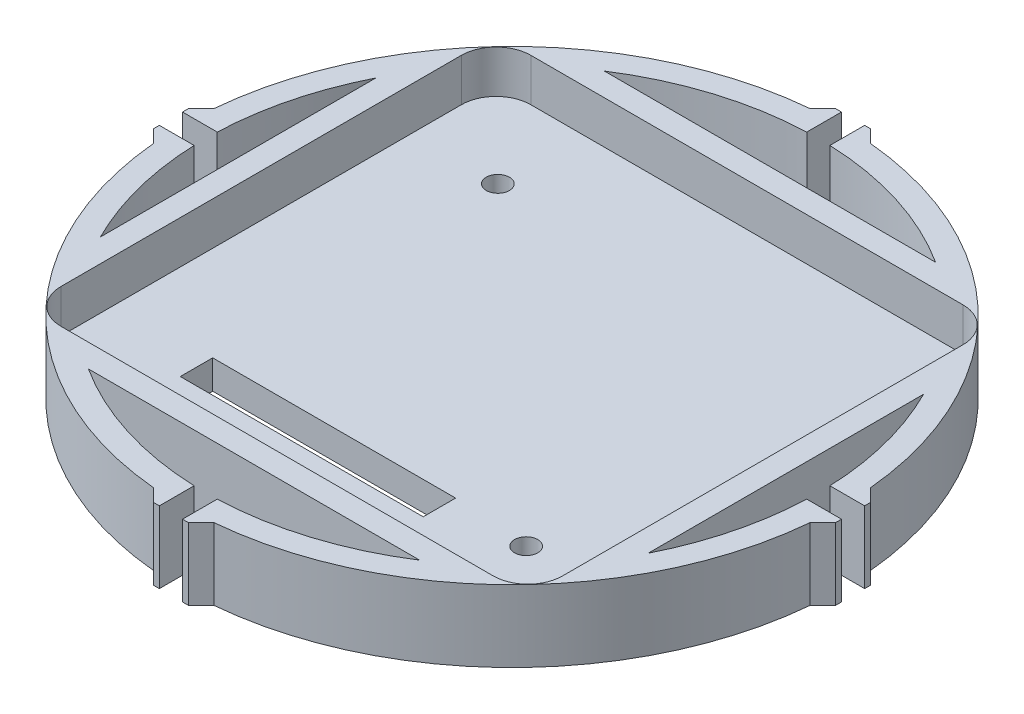
from build123d import *

# Parameters (mm, degrees)
SKETCH1_R           = 28.5
BOSS_EXTRUDE1_DEPTH = 6.2
CUT_EXTRUDE1_DEPTH  = 3.7
CUT_EXTRUDE2_REACH  = 42.475
SKETCH3_R           = 1
SKETCH3_W           = 21
SKETCH3_H           = 2.8
CUT_EXTRUDE3_REACH  = 42.779
BOSS_EXTRUDE2_DEPTH = 6.2


with BuildPart() as part:
    # Sketch1 → Boss-Extrude1 (new body)
    with BuildSketch(Plane(origin=(0, 0, 0), x_dir=(1, 0, 0), z_dir=(0, 1, 0))):
        with Locations(Location((0, 0, 0), (0, 0, 90))):
            Circle(SKETCH1_R)
    extrude(amount=BOSS_EXTRUDE1_DEPTH)

    # Sketch2 → Cut-Extrude1 (cut)
    with BuildSketch(Plane(origin=(0, 6.2, 0), x_dir=(1, 0, 0), z_dir=(0, 1, 0))):
        with BuildLine():
            Line((18.675, 20.3), (-18.675, 20.3))
            ThreePointArc((-18.675, 20.3), (-20.796320344, 19.421320344), (-21.675, 17.3))
            Line((-21.675, 17.3), (-21.675, -17.3))
            ThreePointArc((-21.675, -17.3), (-20.796320374, -19.421320313), (-18.675000086, -20.3))
            Line((-18.675000086, -20.3), (18.675, -20.3))
            ThreePointArc((18.675, -20.3), (20.796320344, -19.421320344), (21.675, -17.3))
            Line((21.675, -17.3), (21.675, 17.3))
            ThreePointArc((21.675, 17.3), (20.796320344, 19.421320344), (18.675, 20.3))
        make_face()
    extrude(amount=-CUT_EXTRUDE1_DEPTH, mode=Mode.SUBTRACT)

    # Sketch3 → Cut-Extrude2 (cut, up to next)
    with BuildSketch(Plane(origin=(0, 2.5, 0), x_dir=(1, 0, 0), z_dir=(0, 1, 0)), mode=Mode.PRIVATE) as cut_extrude2_sk1:
        with Locations(Location((-14.175, 12.95, 0), (0, 0, 270))):
            Circle(SKETCH3_R)
    cut_extrude2_tool1 = extrude(cut_extrude2_sk1.sketch, amount=-CUT_EXTRUDE2_REACH, mode=Mode.PRIVATE) & part.part
    # Sketch3 → Cut-Extrude2 (cut, up to next)
    with BuildSketch(Plane(origin=(0, 2.5, 0), x_dir=(1, 0, 0), z_dir=(0, 1, 0)), mode=Mode.PRIVATE) as cut_extrude2_sk2:
        with Locations((-2.975, -13.8)):
            Rectangle(SKETCH3_W, SKETCH3_H)
    cut_extrude2_tool2 = extrude(cut_extrude2_sk2.sketch, amount=-CUT_EXTRUDE2_REACH, mode=Mode.PRIVATE) & part.part
    # Sketch3 → Cut-Extrude2 (cut, up to next)
    with BuildSketch(Plane(origin=(0, 2.5, 0), x_dir=(1, 0, 0), z_dir=(0, 1, 0)), mode=Mode.PRIVATE) as cut_extrude2_sk3:
        with Locations(Location((14.175, -12.95, 0), (0, 0, 270))):
            Circle(SKETCH3_R)
    cut_extrude2_tool3 = extrude(cut_extrude2_sk3.sketch, amount=-CUT_EXTRUDE2_REACH, mode=Mode.PRIVATE) & part.part
    add(cut_extrude2_tool1.solids().sort_by_distance((-14.175, 2.5, -12.95))[0], mode=Mode.SUBTRACT)
    add(cut_extrude2_tool2.solids().sort_by_distance((-2.975, 2.5, 13.8))[0], mode=Mode.SUBTRACT)
    add(cut_extrude2_tool3.solids().sort_by_distance((14.175, 2.5, 12.95))[0], mode=Mode.SUBTRACT)

    # Sketch4 → Cut-Extrude3 (cut, up to next)
    with BuildSketch(Plane(origin=(0, 6.2, 0), x_dir=(1, 0, 0), z_dir=(0, 1, 0)), mode=Mode.PRIVATE) as cut_extrude3_sk1:
        with BuildLine():
            ThreePointArc((-1, 26.481125354), (-7.938429591, 25.283024653), (-14.316424135, 22.3))
            Line((-14.316424135, 22.3), (-1, 22.3))
            Line((-1, 22.3), (-1, 26.481125354))
        make_face()
    cut_extrude3_tool1 = extrude(cut_extrude3_sk1.sketch, amount=-CUT_EXTRUDE3_REACH, mode=Mode.PRIVATE) & part.part
    # Sketch4 → Cut-Extrude3 (cut, up to next)
    with BuildSketch(Plane(origin=(0, 6.2, 0), x_dir=(1, 0, 0), z_dir=(0, 1, 0)), mode=Mode.PRIVATE) as cut_extrude3_sk2:
        with BuildLine():
            Line((1, 26.481125354), (1, 22.3))
            Line((1, 22.3), (14.316424135, 22.3))
            ThreePointArc((14.316424135, 22.3), (7.938429591, 25.283024653), (1, 26.481125354))
        make_face()
    cut_extrude3_tool2 = extrude(cut_extrude3_sk2.sketch, amount=-CUT_EXTRUDE3_REACH, mode=Mode.PRIVATE) & part.part
    # Sketch4 → Cut-Extrude3 (cut, up to next)
    with BuildSketch(Plane(origin=(0, 6.2, 0), x_dir=(1, 0, 0), z_dir=(0, 1, 0)), mode=Mode.PRIVATE) as cut_extrude3_sk3:
        with BuildLine():
            ThreePointArc((0, 28.5), (-0.500076988, 28.495612347), (-1, 28.482450737))
            Line((-1, 28.482450737), (-1, 26.481125354))
            ThreePointArc((-1, 26.481125354), (0, 26.5), (1, 26.481125354))
            Line((1, 26.481125354), (1, 28.482450737))
            ThreePointArc((1, 28.482450737), (0.500076988, 28.495612347), (0, 28.5))
        make_face()
    cut_extrude3_tool3 = extrude(cut_extrude3_sk3.sketch, amount=-CUT_EXTRUDE3_REACH, mode=Mode.PRIVATE) & part.part
    # Sketch4 → Cut-Extrude3 (cut, up to next)
    with BuildSketch(Plane(origin=(0, 6.2, 0), x_dir=(1, 0, 0), z_dir=(0, 1, 0)), mode=Mode.PRIVATE) as cut_extrude3_sk4:
        with BuildLine():
            Line((-1, -26.481125354), (-1, -28.482450737))
            ThreePointArc((-1, -28.482450737), (-0.500077047, -28.495612346), (-1.18e-07, -28.5))
            ThreePointArc((-1.18e-07, -28.5), (0.500076929, -28.495612348), (1, -28.482450737))
            Line((1, -28.482450737), (1, -26.481125354))
            ThreePointArc((1, -26.481125354), (0, -26.5), (-1, -26.481125354))
        make_face()
    cut_extrude3_tool4 = extrude(cut_extrude3_sk4.sketch, amount=-CUT_EXTRUDE3_REACH, mode=Mode.PRIVATE) & part.part
    # Sketch4 → Cut-Extrude3 (cut, up to next)
    with BuildSketch(Plane(origin=(0, 6.2, 0), x_dir=(1, 0, 0), z_dir=(0, 1, 0)), mode=Mode.PRIVATE) as cut_extrude3_sk5:
        with BuildLine():
            Line((-1, 26.481125354), (-1, 22.3))
            Line((-1, 22.3), (1, 22.3))
            Line((1, 22.3), (1, 26.481125354))
            ThreePointArc((1, 26.481125354), (0, 26.5), (-1, 26.481125354))
        make_face()
    cut_extrude3_tool5 = extrude(cut_extrude3_sk5.sketch, amount=-CUT_EXTRUDE3_REACH, mode=Mode.PRIVATE) & part.part
    # Sketch4 → Cut-Extrude3 (cut, up to next)
    with BuildSketch(Plane(origin=(0, 6.2, 0), x_dir=(1, 0, 0), z_dir=(0, 1, 0)), mode=Mode.PRIVATE) as cut_extrude3_sk6:
        with BuildLine():
            Line((-26.481125354, 1), (-28.482450737, 1))
            ThreePointArc((-28.482450737, 1), (-28.495612347, 0.500076988), (-28.5, 0))
            ThreePointArc((-28.5, 0), (-28.495612347, -0.500076988), (-28.482450737, -1))
            Line((-28.482450737, -1), (-26.481125354, -1))
            ThreePointArc((-26.481125354, -1), (-26.5, 0), (-26.481125354, 1))
        make_face()
    cut_extrude3_tool6 = extrude(cut_extrude3_sk6.sketch, amount=-CUT_EXTRUDE3_REACH, mode=Mode.PRIVATE) & part.part
    # Sketch4 → Cut-Extrude3 (cut, up to next)
    with BuildSketch(Plane(origin=(0, 6.2, 0), x_dir=(1, 0, 0), z_dir=(0, 1, 0)), mode=Mode.PRIVATE) as cut_extrude3_sk7:
        with BuildLine():
            Line((28.482450737, 1), (26.481125354, 1))
            ThreePointArc((26.481125354, 1), (26.495280918, 0.500089055), (26.5, 0))
            ThreePointArc((26.5, 0), (26.495280918, -0.500089055), (26.481125354, -1))
            Line((26.481125354, -1), (28.482450737, -1))
            ThreePointArc((28.482450737, -1), (28.495612347, -0.500076988), (28.5, 0))
            ThreePointArc((28.5, 0), (28.495612347, 0.500076988), (28.482450737, 1))
        make_face()
    cut_extrude3_tool7 = extrude(cut_extrude3_sk7.sketch, amount=-CUT_EXTRUDE3_REACH, mode=Mode.PRIVATE) & part.part
    # Sketch4 → Cut-Extrude3 (cut, up to next)
    with BuildSketch(Plane(origin=(0, 6.2, 0), x_dir=(1, 0, 0), z_dir=(0, 1, 0)), mode=Mode.PRIVATE) as cut_extrude3_sk8:
        with BuildLine():
            Line((-23.675, 1), (-26.481125354, 1))
            ThreePointArc((-26.481125354, 1), (-26.5, 0), (-26.481125354, -1))
            Line((-26.481125354, -1), (-23.675, -1))
            Line((-23.675, -1), (-23.675, 1))
        make_face()
    cut_extrude3_tool8 = extrude(cut_extrude3_sk8.sketch, amount=-CUT_EXTRUDE3_REACH, mode=Mode.PRIVATE) & part.part
    # Sketch4 → Cut-Extrude3 (cut, up to next)
    with BuildSketch(Plane(origin=(0, 6.2, 0), x_dir=(1, 0, 0), z_dir=(0, 1, 0)), mode=Mode.PRIVATE) as cut_extrude3_sk9:
        with BuildLine():
            ThreePointArc((-23.675, 11.90564467), (-25.664031231, 6.603597577), (-26.481125354, 1))
            Line((-26.481125354, 1), (-23.675, 1))
            Line((-23.675, 1), (-23.675, 11.90564467))
        make_face()
    cut_extrude3_tool9 = extrude(cut_extrude3_sk9.sketch, amount=-CUT_EXTRUDE3_REACH, mode=Mode.PRIVATE) & part.part
    # Sketch4 → Cut-Extrude3 (cut, up to next)
    with BuildSketch(Plane(origin=(0, 6.2, 0), x_dir=(1, 0, 0), z_dir=(0, 1, 0)), mode=Mode.PRIVATE) as cut_extrude3_sk10:
        with BuildLine():
            Line((-23.675, -1), (-26.481125354, -1))
            ThreePointArc((-26.481125354, -1), (-25.664031231, -6.603597577), (-23.675, -11.90564467))
            Line((-23.675, -11.90564467), (-23.675, -1))
        make_face()
    cut_extrude3_tool10 = extrude(cut_extrude3_sk10.sketch, amount=-CUT_EXTRUDE3_REACH, mode=Mode.PRIVATE) & part.part
    # Sketch4 → Cut-Extrude3 (cut, up to next)
    with BuildSketch(Plane(origin=(0, 6.2, 0), x_dir=(1, 0, 0), z_dir=(0, 1, 0)), mode=Mode.PRIVATE) as cut_extrude3_sk11:
        with BuildLine():
            Line((-1, -22.3), (-14.316424135, -22.3))
            ThreePointArc((-14.316424135, -22.3), (-7.938429591, -25.283024653), (-1, -26.481125354))
            Line((-1, -26.481125354), (-1, -22.3))
        make_face()
    cut_extrude3_tool11 = extrude(cut_extrude3_sk11.sketch, amount=-CUT_EXTRUDE3_REACH, mode=Mode.PRIVATE) & part.part
    # Sketch4 → Cut-Extrude3 (cut, up to next)
    with BuildSketch(Plane(origin=(0, 6.2, 0), x_dir=(1, 0, 0), z_dir=(0, 1, 0)), mode=Mode.PRIVATE) as cut_extrude3_sk12:
        with BuildLine():
            Line((14.316424135, -22.3), (1, -22.3))
            Line((1, -22.3), (1, -26.481125354))
            ThreePointArc((1, -26.481125354), (7.938429591, -25.283024653), (14.316424135, -22.3))
        make_face()
    cut_extrude3_tool12 = extrude(cut_extrude3_sk12.sketch, amount=-CUT_EXTRUDE3_REACH, mode=Mode.PRIVATE) & part.part
    # Sketch4 → Cut-Extrude3 (cut, up to next)
    with BuildSketch(Plane(origin=(0, 6.2, 0), x_dir=(1, 0, 0), z_dir=(0, 1, 0)), mode=Mode.PRIVATE) as cut_extrude3_sk13:
        with BuildLine():
            Line((1, -22.3), (-1, -22.3))
            Line((-1, -22.3), (-1, -26.481125354))
            ThreePointArc((-1, -26.481125354), (0, -26.5), (1, -26.481125354))
            Line((1, -26.481125354), (1, -22.3))
        make_face()
    cut_extrude3_tool13 = extrude(cut_extrude3_sk13.sketch, amount=-CUT_EXTRUDE3_REACH, mode=Mode.PRIVATE) & part.part
    # Sketch4 → Cut-Extrude3 (cut, up to next)
    with BuildSketch(Plane(origin=(0, 6.2, 0), x_dir=(1, 0, 0), z_dir=(0, 1, 0)), mode=Mode.PRIVATE) as cut_extrude3_sk14:
        with BuildLine():
            ThreePointArc((0, 28.5), (-0.500076988, 28.495612347), (-1, 28.482450737))
            Line((-1, 28.482450737), (-1, 26.481125354))
            ThreePointArc((-1, 26.481125354), (0, 26.5), (1, 26.481125354))
            Line((1, 26.481125354), (1, 28.482450737))
            ThreePointArc((1, 28.482450737), (0.500076988, 28.495612347), (0, 28.5))
        make_face()
    cut_extrude3_tool14 = extrude(cut_extrude3_sk14.sketch, amount=-CUT_EXTRUDE3_REACH, mode=Mode.PRIVATE) & part.part
    # Sketch4 → Cut-Extrude3 (cut, up to next)
    with BuildSketch(Plane(origin=(0, 6.2, 0), x_dir=(1, 0, 0), z_dir=(0, 1, 0)), mode=Mode.PRIVATE) as cut_extrude3_sk15:
        with BuildLine():
            Line((-1, -26.481125354), (-1, -28.482450737))
            ThreePointArc((-1, -28.482450737), (-0.500077047, -28.495612346), (-1.18e-07, -28.5))
            ThreePointArc((-1.18e-07, -28.5), (0.500076929, -28.495612348), (1, -28.482450737))
            Line((1, -28.482450737), (1, -26.481125354))
            ThreePointArc((1, -26.481125354), (0, -26.5), (-1, -26.481125354))
        make_face()
    cut_extrude3_tool15 = extrude(cut_extrude3_sk15.sketch, amount=-CUT_EXTRUDE3_REACH, mode=Mode.PRIVATE) & part.part
    # Sketch4 → Cut-Extrude3 (cut, up to next)
    with BuildSketch(Plane(origin=(0, 6.2, 0), x_dir=(1, 0, 0), z_dir=(0, 1, 0)), mode=Mode.PRIVATE) as cut_extrude3_sk16:
        with BuildLine():
            Line((23.675, 11.90564467), (23.675, 1))
            Line((23.675, 1), (26.481125354, 1))
            ThreePointArc((26.481125354, 1), (25.664031231, 6.603597577), (23.675, 11.90564467))
        make_face()
    cut_extrude3_tool16 = extrude(cut_extrude3_sk16.sketch, amount=-CUT_EXTRUDE3_REACH, mode=Mode.PRIVATE) & part.part
    # Sketch4 → Cut-Extrude3 (cut, up to next)
    with BuildSketch(Plane(origin=(0, 6.2, 0), x_dir=(1, 0, 0), z_dir=(0, 1, 0)), mode=Mode.PRIVATE) as cut_extrude3_sk17:
        with BuildLine():
            Line((26.481125354, -1), (23.675, -1))
            Line((23.675, -1), (23.675, -11.90564467))
            ThreePointArc((23.675, -11.90564467), (25.664031231, -6.603597577), (26.481125354, -1))
        make_face()
    cut_extrude3_tool17 = extrude(cut_extrude3_sk17.sketch, amount=-CUT_EXTRUDE3_REACH, mode=Mode.PRIVATE) & part.part
    # Sketch4 → Cut-Extrude3 (cut, up to next)
    with BuildSketch(Plane(origin=(0, 6.2, 0), x_dir=(1, 0, 0), z_dir=(0, 1, 0)), mode=Mode.PRIVATE) as cut_extrude3_sk18:
        with BuildLine():
            Line((26.481125354, 1), (23.675, 1))
            Line((23.675, 1), (23.675, -1))
            Line((23.675, -1), (26.481125354, -1))
            ThreePointArc((26.481125354, -1), (26.495280918, -0.500089055), (26.5, 0))
            ThreePointArc((26.5, 0), (26.495280918, 0.500089055), (26.481125354, 1))
        make_face()
    cut_extrude3_tool18 = extrude(cut_extrude3_sk18.sketch, amount=-CUT_EXTRUDE3_REACH, mode=Mode.PRIVATE) & part.part
    # Sketch4 → Cut-Extrude3 (cut, up to next)
    with BuildSketch(Plane(origin=(0, 6.2, 0), x_dir=(1, 0, 0), z_dir=(0, 1, 0)), mode=Mode.PRIVATE) as cut_extrude3_sk19:
        with BuildLine():
            Line((-26.481125354, 1), (-28.482450737, 1))
            ThreePointArc((-28.482450737, 1), (-28.495612347, 0.500076988), (-28.5, 0))
            ThreePointArc((-28.5, 0), (-28.495612347, -0.500076988), (-28.482450737, -1))
            Line((-28.482450737, -1), (-26.481125354, -1))
            ThreePointArc((-26.481125354, -1), (-26.5, 0), (-26.481125354, 1))
        make_face()
    cut_extrude3_tool19 = extrude(cut_extrude3_sk19.sketch, amount=-CUT_EXTRUDE3_REACH, mode=Mode.PRIVATE) & part.part
    # Sketch4 → Cut-Extrude3 (cut, up to next)
    with BuildSketch(Plane(origin=(0, 6.2, 0), x_dir=(1, 0, 0), z_dir=(0, 1, 0)), mode=Mode.PRIVATE) as cut_extrude3_sk20:
        with BuildLine():
            Line((28.482450737, 1), (26.481125354, 1))
            ThreePointArc((26.481125354, 1), (26.495280918, 0.500089055), (26.5, 0))
            ThreePointArc((26.5, 0), (26.495280918, -0.500089055), (26.481125354, -1))
            Line((26.481125354, -1), (28.482450737, -1))
            ThreePointArc((28.482450737, -1), (28.495612347, -0.500076988), (28.5, 0))
            ThreePointArc((28.5, 0), (28.495612347, 0.500076988), (28.482450737, 1))
        make_face()
    cut_extrude3_tool20 = extrude(cut_extrude3_sk20.sketch, amount=-CUT_EXTRUDE3_REACH, mode=Mode.PRIVATE) & part.part
    add(cut_extrude3_tool1.solids().sort_by_distance((-5.995694, 6.2, -23.945534))[0], mode=Mode.SUBTRACT)
    add(cut_extrude3_tool2.solids().sort_by_distance((5.995694, 6.2, -23.945534))[0], mode=Mode.SUBTRACT)
    add(cut_extrude3_tool3.solids().sort_by_distance((0, 6.2, -27.493929))[0], mode=Mode.SUBTRACT)
    add(cut_extrude3_tool4.solids().sort_by_distance((0, 6.2, 27.493929))[0], mode=Mode.SUBTRACT)
    add(cut_extrude3_tool5.solids().sort_by_distance((0, 6.2, -24.396858))[0], mode=Mode.SUBTRACT)
    add(cut_extrude3_tool6.solids().sort_by_distance((-27.493929, 6.2, 0))[0], mode=Mode.SUBTRACT)
    add(cut_extrude3_tool7.solids().sort_by_distance((27.493929, 6.2, 0))[0], mode=Mode.SUBTRACT)
    add(cut_extrude3_tool8.solids().sort_by_distance((-25.08436, 6.2, 0))[0], mode=Mode.SUBTRACT)
    add(cut_extrude3_tool9.solids().sort_by_distance((-24.771422, 6.2, -5.065858))[0], mode=Mode.SUBTRACT)
    add(cut_extrude3_tool10.solids().sort_by_distance((-24.771422, 6.2, 5.065858))[0], mode=Mode.SUBTRACT)
    add(cut_extrude3_tool11.solids().sort_by_distance((-5.995694, 6.2, 23.945534))[0], mode=Mode.SUBTRACT)
    add(cut_extrude3_tool12.solids().sort_by_distance((5.995694, 6.2, 23.945534))[0], mode=Mode.SUBTRACT)
    add(cut_extrude3_tool13.solids().sort_by_distance((0, 6.2, 24.396858))[0], mode=Mode.SUBTRACT)
    add(cut_extrude3_tool14.solids().sort_by_distance((0, 6.2, -27.493929))[0], mode=Mode.SUBTRACT)
    add(cut_extrude3_tool15.solids().sort_by_distance((0, 6.2, 27.493929))[0], mode=Mode.SUBTRACT)
    add(cut_extrude3_tool16.solids().sort_by_distance((24.771422, 6.2, -5.065858))[0], mode=Mode.SUBTRACT)
    add(cut_extrude3_tool17.solids().sort_by_distance((24.771422, 6.2, 5.065858))[0], mode=Mode.SUBTRACT)
    add(cut_extrude3_tool18.solids().sort_by_distance((25.08436, 6.2, 0))[0], mode=Mode.SUBTRACT)
    add(cut_extrude3_tool19.solids().sort_by_distance((-27.493929, 6.2, 0))[0], mode=Mode.SUBTRACT)
    add(cut_extrude3_tool20.solids().sort_by_distance((27.493929, 6.2, 0))[0], mode=Mode.SUBTRACT)

    # Sketch5 → Boss-Extrude2 (add)
    with BuildSketch(Plane(origin=(0, 6.2, 0), x_dir=(1, 0, 0), z_dir=(0, 1, 0))):
        with BuildLine():
            ThreePointArc((-2.601425658, 28.381025079), (-1.801426791, 28.443010767), (-1, 28.482450737))
            Line((-1, 28.482450737), (-1, 29.482450737))
            Line((-1, 29.482450737), (-1.5, 29.482450737))
            Line((-1.5, 29.482450737), (-2.601425658, 28.381025079))
        make_face()
        with BuildLine():
            Line((1, 29.482450737), (1, 28.482450737))
            ThreePointArc((1, 28.482450737), (1.801426791, 28.443010767), (2.601425658, 28.381025079))
            Line((2.601425658, 28.381025079), (1.5, 29.482450737))
            Line((1.5, 29.482450737), (1, 29.482450737))
        make_face()
        with BuildLine():
            Line((29.482450737, 1.5), (28.381025079, 2.601425658))
            ThreePointArc((28.381025079, 2.601425658), (28.443010767, 1.801426791), (28.482450737, 1))
            Line((28.482450737, 1), (29.482450737, 1))
            Line((29.482450737, 1), (29.482450737, 1.5))
        make_face()
        with BuildLine():
            Line((29.482450737, -1), (28.482450737, -1))
            ThreePointArc((28.482450737, -1), (28.443010767, -1.801426791), (28.381025079, -2.601425658))
            Line((28.381025079, -2.601425658), (29.482450737, -1.5))
            Line((29.482450737, -1.5), (29.482450737, -1))
        make_face()
        with BuildLine():
            ThreePointArc((-28.381025079, -2.601425658), (-28.443010767, -1.801426791), (-28.482450737, -1))
            Line((-28.482450737, -1), (-29.482450737, -1))
            Line((-29.482450737, -1), (-29.482450737, -1.5))
            Line((-29.482450737, -1.5), (-28.381025079, -2.601425658))
        make_face()
        with BuildLine():
            ThreePointArc((-28.482450737, 1), (-28.443010767, 1.801426791), (-28.381025079, 2.601425658))
            Line((-28.381025079, 2.601425658), (-29.482450737, 1.5))
            Line((-29.482450737, 1.5), (-29.482450737, 1))
            Line((-29.482450737, 1), (-28.482450737, 1))
        make_face()
        with BuildLine():
            ThreePointArc((-1, -28.482450737), (-1.801426791, -28.443010767), (-2.601425658, -28.381025079))
            Line((-2.601425658, -28.381025079), (-1.5, -29.482450737))
            Line((-1.5, -29.482450737), (-1, -29.482450737))
            Line((-1, -29.482450737), (-1, -28.482450737))
        make_face()
        with BuildLine():
            Line((1.5, -29.482450737), (2.601425658, -28.381025079))
            ThreePointArc((2.601425658, -28.381025079), (1.801426791, -28.443010767), (1, -28.482450737))
            Line((1, -28.482450737), (1, -29.482450737))
            Line((1, -29.482450737), (1.5, -29.482450737))
        make_face()
    extrude(amount=-BOSS_EXTRUDE2_DEPTH)


solid = part.part
